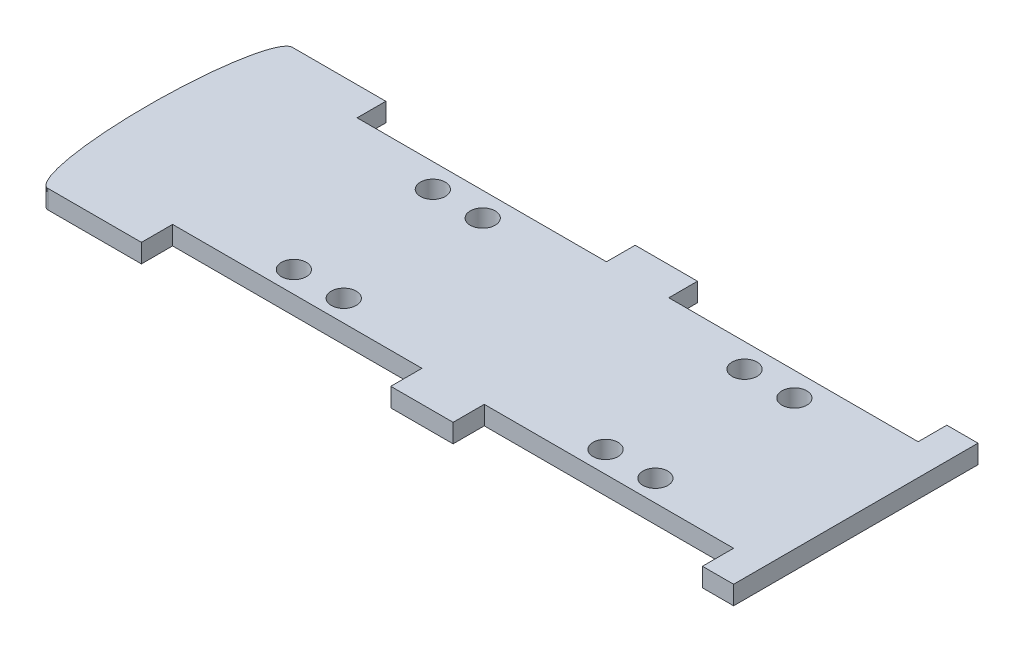
from build123d import *

# Parameters (mm, degrees)
SKETCH_1_R      = 20
EXTRUDE_2_DEPTH = 30


with BuildPart() as part:
    # 草图1 → 凸台-拉伸2 (new body)
    with BuildSketch(Plane(origin=(0, 0, 0), x_dir=(1, 0, 0), z_dir=(0, 1, 0))):
        with BuildLine():
            add(Edge.make_bspline(
                [(-550, -196.023808283), (-515, -196.023808283), (-515, 0), (-515, 196.023808283), (-550, 196.023808283)],
                knots=[0, 0, 0, 1.570796327, 1.570796327, 3.141592654, 3.141592654, 3.141592654], degree=2, weights=[1, 0.707106781, 1, 0.707106781, 1]))
            Line((-550, -196.023808283), (-400, -196.023808283))
            Line((-400, -196.023808283), (-400, -146.023808283))
            Line((-400, -146.023808283), (0, -146.023808283))
            Line((0, -146.023808283), (0, -196.023808283))
            Line((0, -196.023808283), (100, -196.023808283))
            Line((100, -196.023808283), (100, -146.023808283))
            Line((100, -146.023808283), (500, -146.023808283))
            Line((500, -146.023808283), (500, -196.023808283))
            Line((500, -196.023808283), (550, -196.023808283))
            Line((550, -196.023808283), (550, 196.023808283))
            Line((550, 196.023808283), (500, 196.023808283))
            Line((500, 196.023808283), (500, 150))
            Line((500, 150), (100, 150))
            Line((100, 150), (100, 196.023808283))
            Line((100, 196.023808283), (0, 196.023808283))
            Line((0, 196.023808283), (0, 150))
            Line((0, 150), (-400, 150))
            Line((-400, 150), (-400, 196.023808283))
            Line((-400, 196.023808283), (-550, 196.023808283))
        make_face()
        with Locations((-240, -111.462676562)):
            Circle(SKETCH_1_R, mode=Mode.SUBTRACT)
        with Locations((-160, -111.462676562)):
            Circle(SKETCH_1_R, mode=Mode.SUBTRACT)
        with Locations((260, -111.462676562)):
            Circle(SKETCH_1_R, mode=Mode.SUBTRACT)
        with Locations((340, -111.462676562)):
            Circle(SKETCH_1_R, mode=Mode.SUBTRACT)
        with Locations((-240, 111.462676562)):
            Circle(SKETCH_1_R, mode=Mode.SUBTRACT)
        with Locations((-160, 111.462676562)):
            Circle(SKETCH_1_R, mode=Mode.SUBTRACT)
        with Locations((260, 111.462676562)):
            Circle(SKETCH_1_R, mode=Mode.SUBTRACT)
        with Locations((340, 111.462676562)):
            Circle(SKETCH_1_R, mode=Mode.SUBTRACT)
        with BuildLine():
            add(Edge.make_bspline(
                [(-550, 196.023808283), (-585, 196.023808283), (-585, 0), (-585, -196.023808283), (-550, -196.023808283)],
                knots=[3.141592654, 3.141592654, 3.141592654, 4.71238898, 4.71238898, 6.283185307, 6.283185307, 6.283185307], degree=2, weights=[1, 0.707106781, 1, 0.707106781, 1]))
            Line((-550, -196.023808283), (-550, 196.023808283))
        make_face()
        with BuildLine():
            Line((-550, 196.023808283), (-550, -196.023808283))
            add(Edge.make_bspline(
                [(-550, -196.023808283), (-515, -196.023808283), (-515, 0), (-515, 196.023808283), (-550, 196.023808283)],
                knots=[0, 0, 0, 1.570796327, 1.570796327, 3.141592654, 3.141592654, 3.141592654], degree=2, weights=[1, 0.707106781, 1, 0.707106781, 1]))
        make_face()
    extrude(amount=EXTRUDE_2_DEPTH)


solid = part.part
